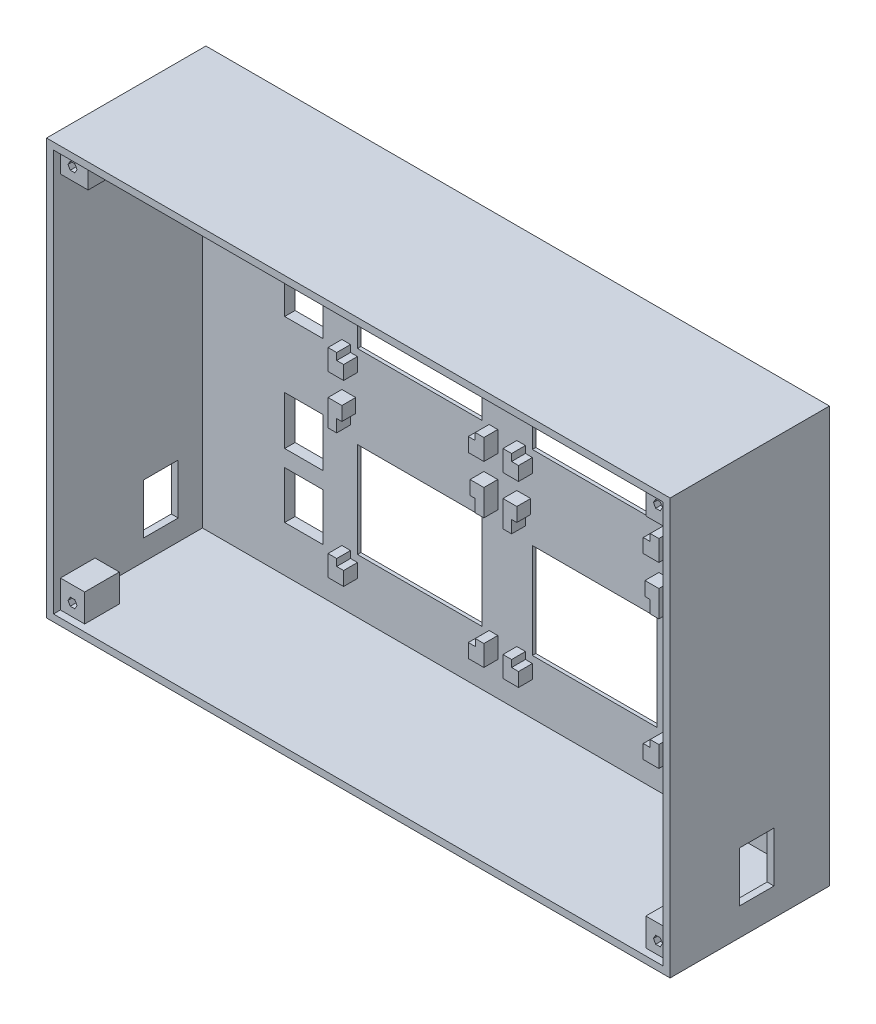
from build123d import *

# Parameters (mm, degrees)
SKETCH1_W            = 180
SKETCH1_H            = 120
BOSS_EXTRUDE_DEPTH   = 46
SKETCH2_W            = 176
SKETCH2_H            = 116
MAIN_BOX_DEPTH       = 43
SKETCH3_W            = 36
SKETCH3_H            = 27.5
DISPLAY_DEPTH        = 4
SKETCH36_W           = 4
SKETCH36_H           = 7.6
BOSS_EXTRUDE8_DEPTH  = 4
SKETCH39_W           = 1.5
SKETCH39_H           = 3.6
CUT_EXTRUDE25_DEPTH  = 4
SKETCH38_W           = 1.5
SKETCH38_H           = 3.6
CUT_EXTRUDE24_DEPTH  = 4
SKETCH40_W           = 1.5
SKETCH40_H           = 3.6
CUT_EXTRUDE26_DEPTH  = 4
SKETCH29_W           = 4
SKETCH29_H           = 7.6
BOSS_EXTRUDE4_DEPTH  = 4
SKETCH31_W           = 1.5
SKETCH31_H           = 3.6
CUT_EXTRUDE21_DEPTH  = 4
SKETCH32_W           = 4.5
SKETCH32_H           = 6
BOSS_EXTRUDE5_DEPTH  = 4
SKETCH33_W           = 2
SKETCH33_H           = 2
CUT_EXTRUDE22_DEPTH  = 4
SKETCH34_W           = 4.5
SKETCH34_H           = 6
BOSS_EXTRUDE7_DEPTH  = 4
SKETCH35_W           = 2
SKETCH35_H           = 2
SKETCH35_W_2         = 2.003256869
CUT_EXTRUDE23_DEPTH  = 4
SKETCH43_W           = 1.5
SKETCH43_H           = 3.6
CUT_EXTRUDE28_DEPTH  = 4
SKETCH7_W            = 11
SKETCH7_H            = 14
SKETCH7_H_2          = 13.721191738
PUSH_BUTTON_DEPTH    = 4
SKETCH27_W           = 10
SKETCH27_H           = 14.5
CUT_EXTRUDE17_DEPTH  = 3
SKETCH28_W           = 10
SKETCH28_H           = 14.5
CUT_EXTRUDE18_DEPTH  = 3
SKETCH45_W           = 8
SKETCH45_H           = 16
BOSS_EXTRUDE10_DEPTH = 7
SKETCH46_W           = 16
SKETCH46_H           = 8
BOSS_EXTRUDE11_DEPTH = 7
SKETCH47_W           = 16
SKETCH47_H           = 8
BOSS_EXTRUDE12_DEPTH = 7
SKETCH48_W           = 16
SKETCH48_H           = 8
BOSS_EXTRUDE13_DEPTH = 7
CUT_EXTRUDE29_DEPTH  = 10
SKETCH50_R           = 4
CUT_EXTRUDE30_DEPTH  = 10
CHAMFER1_SIZE        = 6
CHAMFER2_SIZE        = 2


with BuildPart() as part:
    # Sketch1 → Boss-Extrude (new body)
    with BuildSketch(Plane.XY):
        with Locations((11.894772566, 16.201550388)):
            Rectangle(SKETCH1_W, SKETCH1_H)
    extrude(amount=BOSS_EXTRUDE_DEPTH)

    # Sketch2 → Main Box (cut)
    with BuildSketch(Plane.XY.offset(46)):
        with Locations((11.894772566, 16.201550388)):
            Rectangle(SKETCH2_W, SKETCH2_H)
    extrude(amount=-MAIN_BOX_DEPTH, mode=Mode.SUBTRACT)

    # Sketch3 → Display (cut, through all)
    with BuildSketch(Plane.XY.offset(3)):
        with Locations((37.144772566, 39.201550388)):
            Rectangle(SKETCH3_W, SKETCH3_H)
        with Locations((-13.355227434, -12.298449612)):
            Rectangle(SKETCH3_W, SKETCH3_H)
        with Locations((37.144772566, -12.298449612)):
            Rectangle(SKETCH3_W, SKETCH3_H)
        with Locations((-13.355227434, 39.201550388)):
            Rectangle(SKETCH3_W, SKETCH3_H)
    extrude(amount=-DISPLAY_DEPTH, mode=Mode.SUBTRACT)

    # Sketch36 → Boss-Extrude8 (add)
    with BuildSketch(Plane.XY.offset(3)):
        with Locations((-33.855227434, 9.151550388)):
            Rectangle(SKETCH36_W, SKETCH36_H)
        with Locations((7.144772566, 9.151550388)):
            Rectangle(SKETCH36_W, SKETCH36_H)
        with Locations((16.644772566, 9.151550388)):
            Rectangle(SKETCH36_W, SKETCH36_H)
        with Locations((57.644772566, 9.151550388)):
            Rectangle(SKETCH36_W, SKETCH36_H)
    extrude(amount=BOSS_EXTRUDE8_DEPTH)

    # Sketch39 → Cut-Extrude25 (cut)
    with BuildSketch(Plane.XY.offset(7)):
        with Locations((5.894772566, 7.151550388)):
            Rectangle(SKETCH39_W, SKETCH39_H)
    extrude(amount=-CUT_EXTRUDE25_DEPTH, mode=Mode.SUBTRACT)

    # Sketch38 → Cut-Extrude24 (cut)
    with BuildSketch(Plane.XY.offset(7)):
        with Locations((-32.605227434, 7.151550388)):
            Rectangle(SKETCH38_W, SKETCH38_H)
    extrude(amount=-CUT_EXTRUDE24_DEPTH, mode=Mode.SUBTRACT)

    # Sketch40 → Cut-Extrude26 (cut)
    with BuildSketch(Plane.XY.offset(7)):
        with Locations((17.894772566, 7.151550388)):
            Rectangle(SKETCH40_W, SKETCH40_H)
    extrude(amount=-CUT_EXTRUDE26_DEPTH, mode=Mode.SUBTRACT)

    # Sketch29 → Boss-Extrude4 (add)
    with BuildSketch(Plane.XY.offset(3)):
        with Locations((16.644772566, 60.651550388)):
            Rectangle(SKETCH29_W, SKETCH29_H)
        with Locations((57.644772566, 60.651550388)):
            Rectangle(SKETCH29_W, SKETCH29_H)
        with Locations((-33.855227434, 60.651550388)):
            Rectangle(SKETCH29_W, SKETCH29_H)
        with Locations((7.144772566, 60.651550388)):
            Rectangle(SKETCH29_W, SKETCH29_H)
    extrude(amount=BOSS_EXTRUDE4_DEPTH)

    # Sketch31 → Cut-Extrude21 (cut)
    with BuildSketch(Plane.XY.offset(7)):
        with Locations((-32.605227434, 58.651550388)):
            Rectangle(SKETCH31_W, SKETCH31_H)
        with Locations((5.894772566, 58.651550388)):
            Rectangle(SKETCH31_W, SKETCH31_H)
        with Locations((17.894772566, 58.651550388)):
            Rectangle(SKETCH31_W, SKETCH31_H)
        with Locations((56.394772566, 58.651550388)):
            Rectangle(SKETCH31_W, SKETCH31_H)
    extrude(amount=-CUT_EXTRUDE21_DEPTH, mode=Mode.SUBTRACT)

    # Sketch32 → Boss-Extrude5 (add)
    with BuildSketch(Plane.XY.offset(3)):
        with Locations((-33.605227434, 22.451550388)):
            Rectangle(SKETCH32_W, SKETCH32_H)
        with Locations((6.894772566, 22.451550388)):
            Rectangle(SKETCH32_W, SKETCH32_H)
        with Locations((16.894772566, 22.451550388)):
            Rectangle(SKETCH32_W, SKETCH32_H)
        with Locations((57.394772566, 22.451550388)):
            Rectangle(SKETCH32_W, SKETCH32_H)
    extrude(amount=BOSS_EXTRUDE5_DEPTH)

    # Sketch33 → Cut-Extrude22 (cut)
    with BuildSketch(Plane.XY.offset(7)):
        with Locations((-32.355227434, 24.451550388)):
            Rectangle(SKETCH33_W, SKETCH33_H)
        with Locations((5.644772566, 24.451550388)):
            Rectangle(SKETCH33_W, SKETCH33_H)
        with Locations((18.144772566, 24.451550388)):
            Rectangle(SKETCH33_W, SKETCH33_H)
        with Locations((56.144772566, 24.451550388)):
            Rectangle(SKETCH33_W, SKETCH33_H)
    extrude(amount=-CUT_EXTRUDE22_DEPTH, mode=Mode.SUBTRACT)

    # Sketch34 → Boss-Extrude7 (add)
    with BuildSketch(Plane.XY.offset(3)):
        with Locations((-33.605227434, -29.048449612)):
            Rectangle(SKETCH34_W, SKETCH34_H)
        with Locations((6.894772566, -29.048449612)):
            Rectangle(SKETCH34_W, SKETCH34_H)
        with Locations((16.894772566, -29.048449612)):
            Rectangle(SKETCH34_W, SKETCH34_H)
        with Locations((57.394772566, -29.048449612)):
            Rectangle(SKETCH34_W, SKETCH34_H)
    extrude(amount=BOSS_EXTRUDE7_DEPTH)

    # Sketch35 → Cut-Extrude23 (cut)
    with BuildSketch(Plane.XY.offset(7)):
        with Locations((-32.355227434, -27.048449612)):
            Rectangle(SKETCH35_W, SKETCH35_H)
        with Locations((5.646401001, -27.048449612)):
            Rectangle(SKETCH35_W_2, SKETCH35_H)
        with Locations((18.144772566, -27.048449612)):
            Rectangle(SKETCH35_W, SKETCH35_H)
        with Locations((56.144772566, -27.048449612)):
            Rectangle(SKETCH35_W, SKETCH35_H)
    extrude(amount=-CUT_EXTRUDE23_DEPTH, mode=Mode.SUBTRACT)

    # Sketch43 → Cut-Extrude28 (cut)
    with BuildSketch(Plane.XY.offset(7)):
        with Locations((56.394772566, 7.151550388)):
            Rectangle(SKETCH43_W, SKETCH43_H)
    extrude(amount=-CUT_EXTRUDE28_DEPTH, mode=Mode.SUBTRACT)

    # Sketch7 → Push Button (cut, through all)
    with BuildSketch(Plane.XY.offset(3)):
        with Locations((-46.855227434, 29.951550388)):
            Rectangle(SKETCH7_W, SKETCH7_H)
        with Locations((70.644772566, 48.451550388)):
            Rectangle(SKETCH7_W, SKETCH7_H)
        with Locations((70.644772566, 29.951550388)):
            Rectangle(SKETCH7_W, SKETCH7_H)
        with Locations((70.644772566, -3.048449612)):
            Rectangle(SKETCH7_W, SKETCH7_H)
        with Locations((70.644772566, -21.687853743)):
            Rectangle(SKETCH7_W, SKETCH7_H_2)
        with Locations((-46.855227434, -21.687853743)):
            Rectangle(SKETCH7_W, SKETCH7_H_2)
        with Locations((-46.855227434, -3.048449612)):
            Rectangle(SKETCH7_W, SKETCH7_H)
        with Locations((-46.855227434, 48.451550388)):
            Rectangle(SKETCH7_W, SKETCH7_H)
    extrude(amount=-PUSH_BUTTON_DEPTH, mode=Mode.SUBTRACT)

    # Sketch27 → Cut-Extrude17 (cut)
    with BuildSketch(Plane(origin=(101.894772566, 0, 0), x_dir=(0, 0, -1), z_dir=(1, 0, 0))):
        with Locations((-21, -28.548449612)):
            Rectangle(SKETCH27_W, SKETCH27_H)
    extrude(amount=-CUT_EXTRUDE17_DEPTH, mode=Mode.SUBTRACT)

    # Sketch28 → Cut-Extrude18 (cut)
    with BuildSketch(Plane.ZY.offset(78.105227434)):
        with Locations((15, -28.548449612)):
            Rectangle(SKETCH28_W, SKETCH28_H)
    extrude(amount=-CUT_EXTRUDE18_DEPTH, mode=Mode.SUBTRACT)

    # Sketch45 → Boss-Extrude10 (add)
    with BuildSketch(Plane.XZ.offset(-74.201550388)):
        with Locations((-72.105227434, 36)):
            Rectangle(SKETCH45_W, SKETCH45_H)
    extrude(amount=BOSS_EXTRUDE10_DEPTH)

    # Sketch46 → Boss-Extrude11 (add)
    with BuildSketch(Plane.ZY.offset(-99.894772566)):
        with Locations((36, 70.201550388)):
            Rectangle(SKETCH46_W, SKETCH46_H)
    extrude(amount=BOSS_EXTRUDE11_DEPTH)

    # Sketch47 → Boss-Extrude12 (add)
    with BuildSketch(Plane.ZY.offset(-99.894772566)):
        with Locations((36, -37.798449612)):
            Rectangle(SKETCH47_W, SKETCH47_H)
    extrude(amount=BOSS_EXTRUDE12_DEPTH)

    # Sketch48 → Boss-Extrude13 (add)
    with BuildSketch(Plane(origin=(-76.105227434, 0, 0), x_dir=(0, 0, -1), z_dir=(1, 0, 0))):
        with Locations((-36, -37.798449612)):
            Rectangle(SKETCH48_W, SKETCH48_H)
    extrude(amount=BOSS_EXTRUDE13_DEPTH)

    # Sketch49 → Cut-Extrude29 (cut)
    with BuildSketch(Plane.XY.offset(44)):
        Polygon((-73.259927972, 71.835524984), (-73.914628511, 70.701550388), (-73.259927972, 69.567575791), (-71.950526895, 69.567575791), (-71.295826357, 70.701550388), (-71.950526895, 71.835524984), align=None)
        Polygon((-71.950526895, -39.432424209), (-73.259927972, -39.432424209), (-73.914628511, -38.298449612), (-73.259927972, -37.164475016), (-71.950526895, -37.164475016), (-71.295826357, -38.298449612), align=None)
        Polygon((97.049473105, -39.432424209), (97.704173643, -38.298449612), (97.049473105, -37.164475016), (95.740072028, -37.164475016), (95.085371489, -38.298449612), (95.740072028, -39.432424209), align=None)
        Polygon((95.740072028, 69.567575791), (95.085371489, 70.701550388), (95.740072028, 71.835524984), (97.049473105, 71.835524984), (97.704173643, 70.701550388), (97.049473105, 69.567575791), align=None)
    extrude(amount=-CUT_EXTRUDE29_DEPTH, mode=Mode.SUBTRACT)

    # Sketch50 → Cut-Extrude30 (cut)
    with BuildSketch(Plane.ZY.offset(78.105227434)):
        with Locations((23.235294872, 59.215339322)):
            Circle(SKETCH50_R)
    extrude(amount=-CUT_EXTRUDE30_DEPTH, mode=Mode.SUBTRACT)

    # Chamfer1
    chamfer1_edges = [part.edges().sort_by_distance(p)[0] for p in [
        (-68.105227434, 70.701550388, 28),
        (-72.105227434, 67.201550388, 28),
        (96.394772566, 66.201550388, 28),
        (92.894772566, 70.201550388, 28),
        (96.394772566, -33.798449612, 28),
        (92.894772566, -37.798449612, 28),
        (-72.605227434, -33.798449612, 28),
        (-69.105227434, -37.798449612, 28),
    ]]
    chamfer(chamfer1_edges, length=CHAMFER1_SIZE)

    # Chamfer2
    chamfer2_edges = [part.edges().sort_by_distance(p)[0] for p in [
        (-31.355227434, 39.201550388, 0),
        (-13.355227434, 25.451550388, 0),
        (4.644772566, 39.201550388, 0),
        (-13.355227434, 52.951550388, 0),
        (37.144772566, 25.451550388, 0),
        (55.144772566, 39.201550388, 0),
        (37.144772566, 52.951550388, 0),
        (19.144772566, 39.201550388, 0),
        (19.144772566, -12.298449612, 0),
        (37.144772566, -26.048449612, 0),
        (55.144772566, -12.298449612, 0),
        (37.144772566, 1.451550388, 0),
        (-13.355227434, 1.451550388, 0),
        (4.644772566, -12.298449612, 0),
        (-13.355227434, -26.048449612, 0),
        (-31.355227434, -12.298449612, 0),
        (99.894772566, -41.798449612, 15.5),
    ]]
    chamfer(chamfer2_edges, length=CHAMFER2_SIZE)


solid = part.part
